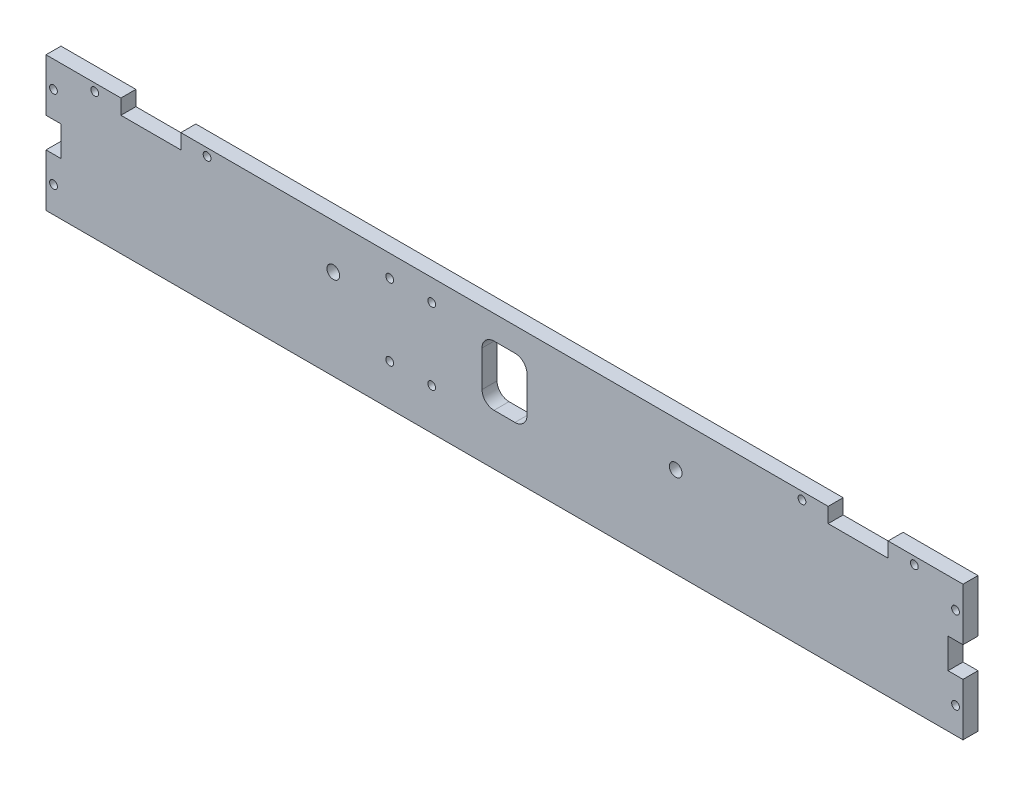
from build123d import *

# Parameters (mm, degrees)
SKETCH1_R           = 1.65
SKETCH1_R_2         = 2.7
BOSS_EXTRUDE1_DEPTH = 6.35
CUT_EXTRUDE1_REACH  = 8.35
SKETCH2_R           = 1.65


with BuildPart() as part:
    # Sketch1 → Boss-Extrude1 (new body)
    with BuildSketch(Plane(origin=(0, 0, 215.9), x_dir=(-1, 0, 0), z_dir=(0, 0, -1))):
        Polygon((50.8, 57.15), (50.8, 50.8), (25.4, 50.8), (25.4, 57.15), (-6.35, 57.15), (-6.35, 34.925), (0, 34.925), (0, 22.225), (-6.35, 22.225), (-6.35, 0), (382.27, 0), (382.27, 22.225), (375.92, 22.225), (375.92, 34.925), (382.27, 34.925), (382.27, 57.15), (350.52, 57.15), (350.52, 50.8), (325.12, 50.8), (325.12, 57.15), align=None)
        with Locations((379.095, 11.1125)):
            Circle(SKETCH1_R, mode=Mode.SUBTRACT)
        with Locations((-3.175, 11.1125)):
            Circle(SKETCH1_R, mode=Mode.SUBTRACT)
        with Locations((379.095, 46.037500912)):
            Circle(SKETCH1_R, mode=Mode.SUBTRACT)
        with Locations((-3.175, 46.037500912)):
            Circle(SKETCH1_R, mode=Mode.SUBTRACT)
        with Locations((314.0075, 53.975)):
            Circle(SKETCH1_R, mode=Mode.SUBTRACT)
        with Locations((61.9125, 53.975)):
            Circle(SKETCH1_R, mode=Mode.SUBTRACT)
        with Locations((361.6325, 53.975)):
            Circle(SKETCH1_R, mode=Mode.SUBTRACT)
        with Locations((14.2875, 53.975)):
            Circle(SKETCH1_R, mode=Mode.SUBTRACT)
        with Locations((260.51, 38.26)):
            Circle(SKETCH1_R_2, mode=Mode.SUBTRACT)
        with Locations((115.41, 38.26)):
            Circle(SKETCH1_R_2, mode=Mode.SUBTRACT)
        with BuildLine():
            Line((192.405, 21.59), (183.515, 21.59))
            ThreePointArc((183.515, 21.59), (179.922897552, 23.077897552), (178.435, 26.67))
            Line((178.435, 26.67), (178.435, 41.91))
            ThreePointArc((178.435, 41.91), (179.922897552, 45.502102448), (183.515, 46.99))
            Line((183.515, 46.99), (192.405, 46.99))
            ThreePointArc((192.405, 46.99), (195.997102448, 45.502102448), (197.485, 41.91))
            Line((197.485, 41.91), (197.485, 26.67))
            ThreePointArc((197.485, 26.67), (195.997102448, 23.077897552), (192.405, 21.59))
        make_face(mode=Mode.SUBTRACT)
    extrude(amount=-BOSS_EXTRUDE1_DEPTH)

    # Sketch2 → Cut-Extrude1 (cut, up to next)
    with BuildSketch(Plane.XY.offset(222.25), mode=Mode.PRIVATE) as cut_extrude1_sk1:
        with Locations((-218.821, 47.9552)):
            Circle(SKETCH2_R)
    cut_extrude1_tool1 = extrude(cut_extrude1_sk1.sketch, amount=-CUT_EXTRUDE1_REACH, mode=Mode.PRIVATE) & part.part
    add(cut_extrude1_tool1.solids().sort_by_distance((-218.821, 47.9552, 222.25))[0], mode=Mode.SUBTRACT)
    # Sketch2 → Cut-Extrude1 (cut, up to next)
    with BuildSketch(Plane.XY.offset(222.25), mode=Mode.PRIVATE) as cut_extrude1_sk2:
        with Locations((-236.601, 47.9552)):
            Circle(SKETCH2_R)
    cut_extrude1_tool2 = extrude(cut_extrude1_sk2.sketch, amount=-CUT_EXTRUDE1_REACH, mode=Mode.PRIVATE) & part.part
    add(cut_extrude1_tool2.solids().sort_by_distance((-236.601, 47.9552, 222.25))[0], mode=Mode.SUBTRACT)
    # Sketch2 → Cut-Extrude1 (cut, up to next)
    with BuildSketch(Plane.XY.offset(222.25), mode=Mode.PRIVATE) as cut_extrude1_sk3:
        with Locations((-236.601, 17.4752)):
            Circle(SKETCH2_R)
    cut_extrude1_tool3 = extrude(cut_extrude1_sk3.sketch, amount=-CUT_EXTRUDE1_REACH, mode=Mode.PRIVATE) & part.part
    add(cut_extrude1_tool3.solids().sort_by_distance((-236.601, 17.4752, 222.25))[0], mode=Mode.SUBTRACT)
    # Sketch2 → Cut-Extrude1 (cut, up to next)
    with BuildSketch(Plane.XY.offset(222.25), mode=Mode.PRIVATE) as cut_extrude1_sk4:
        with Locations((-218.821, 17.4752)):
            Circle(SKETCH2_R)
    cut_extrude1_tool4 = extrude(cut_extrude1_sk4.sketch, amount=-CUT_EXTRUDE1_REACH, mode=Mode.PRIVATE) & part.part
    add(cut_extrude1_tool4.solids().sort_by_distance((-218.821, 17.4752, 222.25))[0], mode=Mode.SUBTRACT)


solid = part.part
